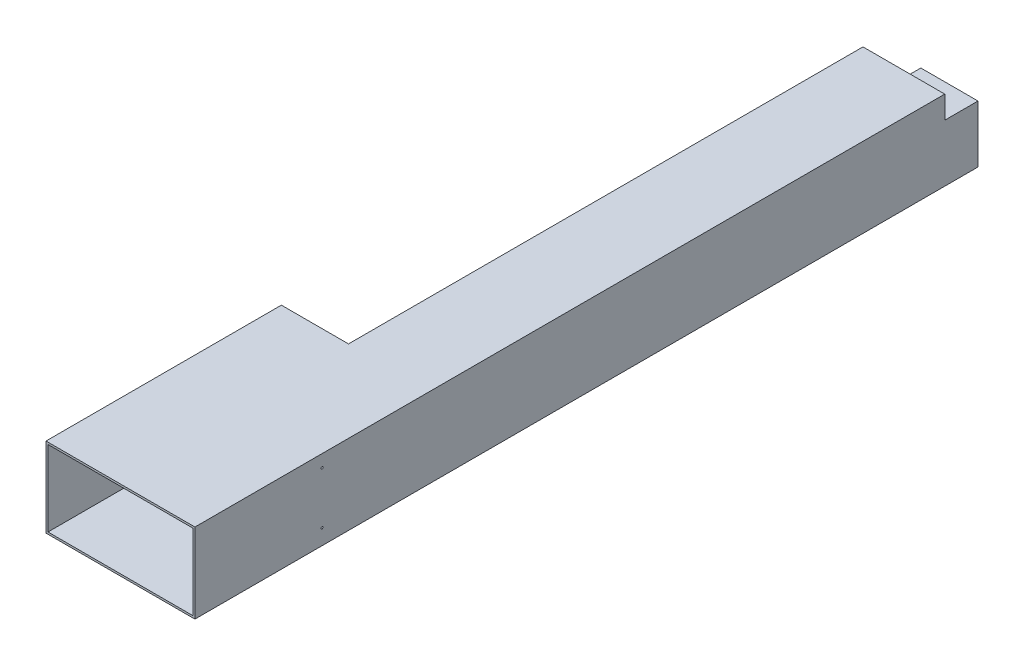
from build123d import *

# Parameters (mm, degrees)
SKETCH1_W          = 11200
SKETCH1_H          = 6000
SKETCH1_W_2        = 10900
SKETCH1_H_2        = 5700
EXTRUDE1_DEPTH     = 17700
SKETCH2_W          = 6150
SKETCH2_H          = 6000
SKETCH2_W_2        = 5850
SKETCH2_H_2        = 5700
EXTRUDE2_DEPTH     = 38540
SKETCH3_W          = 4300
SKETCH3_H          = 4300
SKETCH3_W_2        = 4000
SKETCH3_H_2        = 4000
EXTRUDE3_DEPTH     = 2500
SKETCH4_W          = 4300
SKETCH4_H          = 4300
EXTRUDE4_DEPTH     = 150
EXTRUDE5_DEPTH     = 150
SKETCH6_W          = 5200
SKETCH6_H          = 6000
EXTRUDE7_DEPTH     = 150
CUT_EXTRUDE1_REACH = 11202
SKETCH7_R          = 75
CUT_EXTRUDE2_REACH = 6002
SKETCH8_R          = 50


with BuildPart() as part:
    # Sketch1 → Extrude1 (new body)
    with BuildSketch(Plane.XY):
        with Locations((5450, 2850)):
            Rectangle(SKETCH1_W, SKETCH1_H)
        with Locations((5450, 2850)):
            Rectangle(SKETCH1_W_2, SKETCH1_H_2, mode=Mode.SUBTRACT)
    extrude(amount=-EXTRUDE1_DEPTH)

    # Sketch2 → Extrude2 (add)
    with BuildSketch(Plane(origin=(0, 0, -56240), x_dir=(-1, 0, 0), z_dir=(0, 0, -1))):
        with Locations((-7975, 2850)):
            Rectangle(SKETCH2_W, SKETCH2_H)
        with Locations((-7975, 2850)):
            Rectangle(SKETCH2_W_2, SKETCH2_H_2, mode=Mode.SUBTRACT)
    extrude(amount=-EXTRUDE2_DEPTH)

    # Sketch3 → Extrude3 (add)
    with BuildSketch(Plane(origin=(0, 0, -58740), x_dir=(-1, 0, 0), z_dir=(0, 0, -1))):
        with Locations((-8900, 2000)):
            Rectangle(SKETCH3_W, SKETCH3_H)
        with Locations((-8900, 2000)):
            Rectangle(SKETCH3_W_2, SKETCH3_H_2, mode=Mode.SUBTRACT)
    extrude(amount=-EXTRUDE3_DEPTH)

    # Sketch4 → Extrude4 (add)
    with BuildSketch(Plane(origin=(0, 0, -58740), x_dir=(-1, 0, 0), z_dir=(0, 0, -1))):
        with Locations((-8900, 2000)):
            Rectangle(SKETCH4_W, SKETCH4_H)
    extrude(amount=EXTRUDE4_DEPTH)

    # Sketch5 → Extrude5 (add)
    with BuildSketch(Plane(origin=(0, 0, -56240), x_dir=(-1, 0, 0), z_dir=(0, 0, -1))):
        Polygon((-11050, 5850), (-11050, 4150), (-6750, 4150), (-6750, -150), (-4900, -150), (-4900, 5850), align=None)
    extrude(amount=EXTRUDE5_DEPTH)

    # Sketch6 → Extrude7 (add)
    with BuildSketch(Plane(origin=(0, 0, -17700), x_dir=(-1, 0, 0), z_dir=(0, 0, -1))):
        with Locations((-2450, 2850)):
            Rectangle(SKETCH6_W, SKETCH6_H)
    extrude(amount=-EXTRUDE7_DEPTH)

    # Sketch7 → Cut-Extrude1 (cut, up to next)
    with BuildSketch(Plane(origin=(11050, 0, 0), x_dir=(0, 0, -1), z_dir=(1, 0, 0)), mode=Mode.PRIVATE) as cut_extrude1_sk1:
        with Locations((9560, 4920)):
            Circle(SKETCH7_R)
    cut_extrude1_tool1 = extrude(cut_extrude1_sk1.sketch, amount=-CUT_EXTRUDE1_REACH, mode=Mode.PRIVATE) & part.part
    add(cut_extrude1_tool1.solids().sort_by_distance((11050, 4920, -9560))[0], mode=Mode.SUBTRACT)
    # Sketch7 → Cut-Extrude1 (cut, up to next)
    with BuildSketch(Plane(origin=(11050, 0, 0), x_dir=(0, 0, -1), z_dir=(1, 0, 0)), mode=Mode.PRIVATE) as cut_extrude1_sk2:
        with Locations((9560, 1020)):
            Circle(SKETCH7_R)
    cut_extrude1_tool2 = extrude(cut_extrude1_sk2.sketch, amount=-CUT_EXTRUDE1_REACH, mode=Mode.PRIVATE) & part.part
    add(cut_extrude1_tool2.solids().sort_by_distance((11050, 1020, -9560))[0], mode=Mode.SUBTRACT)

    # Sketch8 → Cut-Extrude2 (cut, up to next)
    with BuildSketch(Plane.XZ.offset(150), mode=Mode.PRIVATE) as cut_extrude2_sk1:
        with Locations(Location((8050, -22960, 0), (0, 0, 270))):  # turned: the seam where the file's is
            Circle(SKETCH8_R)
    cut_extrude2_tool1 = extrude(cut_extrude2_sk1.sketch, amount=-CUT_EXTRUDE2_REACH, mode=Mode.PRIVATE) & part.part
    add(cut_extrude2_tool1.solids().sort_by_distance((8050, -150, -22960))[0], mode=Mode.SUBTRACT)


solid = part.part
